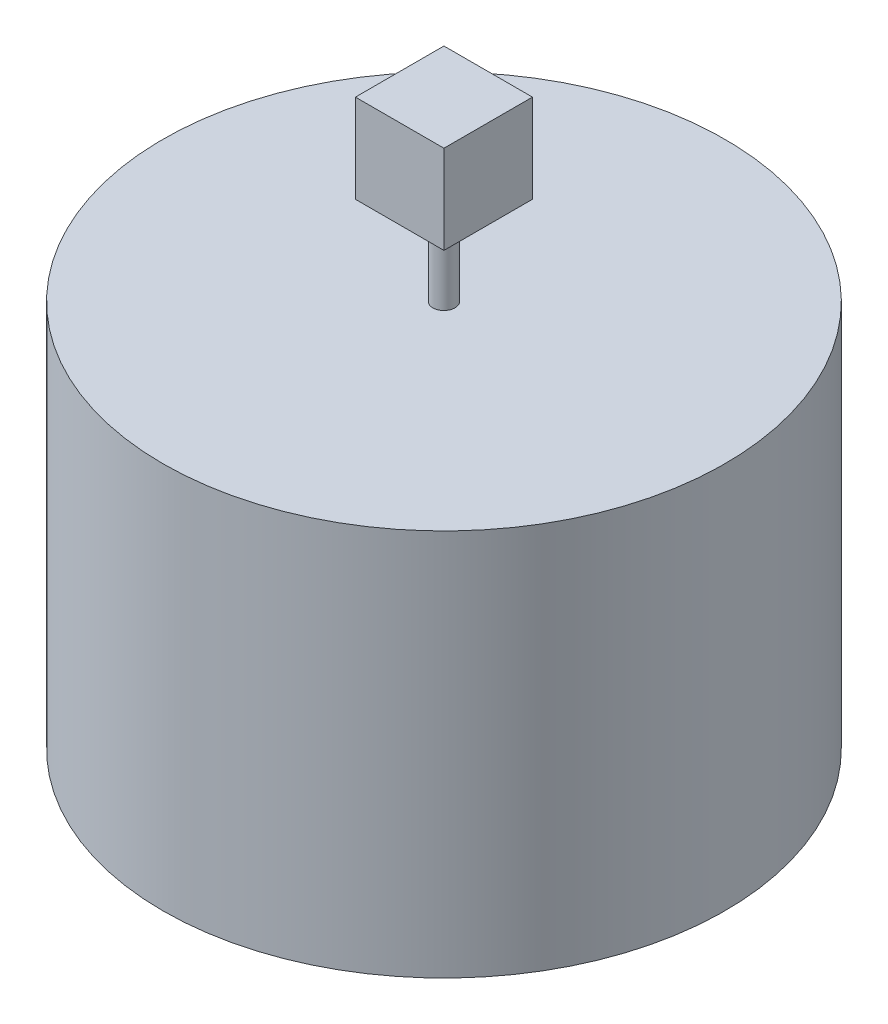
from build123d import *

# Parameters (mm, degrees)
ESQUISSE1_R      = 254
EXTRUSION1_DEPTH = 350
ESQUISSE2_R      = 10
EXTRUSION2_DEPTH = 80
ESQUISSE3_W      = 80
ESQUISSE3_H      = 80
EXTRUSION3_DEPTH = 80


with BuildPart() as part:
    # Esquisse1 → Extrusion1 (new body)
    with BuildSketch(Plane(origin=(0, 0, 0), x_dir=(1, 0, 0), z_dir=(0, 1, 0))):
        Circle(ESQUISSE1_R)
    extrude(amount=EXTRUSION1_DEPTH)

    # Esquisse2 → Extrusion2 (add)
    with BuildSketch(Plane(origin=(0, 350, 0), x_dir=(1, 0, 0), z_dir=(0, 1, 0))):
        Circle(ESQUISSE2_R)
    extrude(amount=EXTRUSION2_DEPTH)

    # Esquisse3 → Extrusion3 (add)
    with BuildSketch(Plane(origin=(0, 430, 0), x_dir=(1, 0, 0), z_dir=(0, 1, 0))):
        Rectangle(ESQUISSE3_W, ESQUISSE3_H)
    extrude(amount=EXTRUSION3_DEPTH)


solid = part.part
